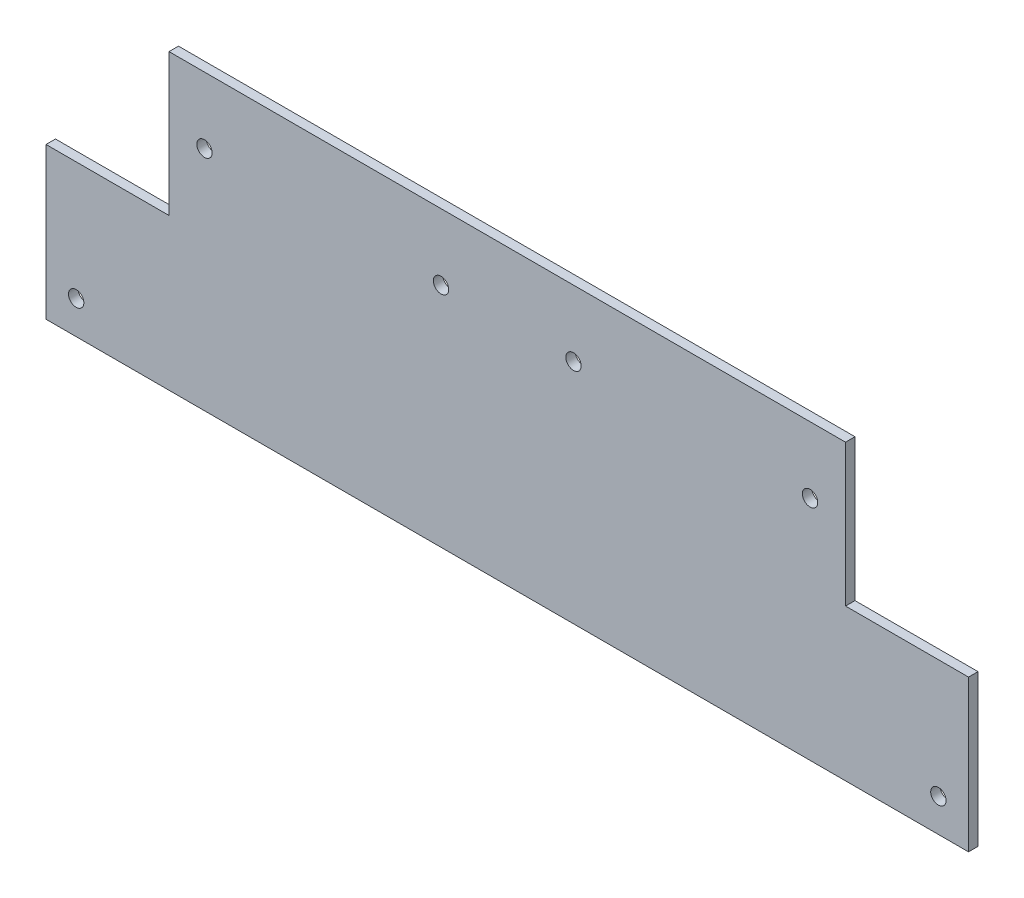
from build123d import *

# Parameters (mm, degrees)
CROQUIS1_R              = 1.625
SALIENTE_EXTRUIR1_DEPTH = 2


with BuildPart() as part:
    # Croquis1 → Saliente-Extruir1 (new body)
    with BuildSketch(Plane.XY):
        Polygon((-97.5, 0), (97.5, 0), (97.5, 32), (71.5, 32), (71.5, 62), (-71.5, 62), (-71.5, 32), (-97.5, 32), align=None)
        with Locations((91.125, 7)):
            Circle(CROQUIS1_R, mode=Mode.SUBTRACT)
        with Locations((64, 48)):
            Circle(CROQUIS1_R, mode=Mode.SUBTRACT)
        with Locations((14, 48)):
            Circle(CROQUIS1_R, mode=Mode.SUBTRACT)
        with Locations((-14, 48)):
            Circle(CROQUIS1_R, mode=Mode.SUBTRACT)
        with Locations((-64, 48)):
            Circle(CROQUIS1_R, mode=Mode.SUBTRACT)
        with Locations((-91.125, 7)):
            Circle(CROQUIS1_R, mode=Mode.SUBTRACT)
    extrude(amount=SALIENTE_EXTRUIR1_DEPTH)


solid = part.part
